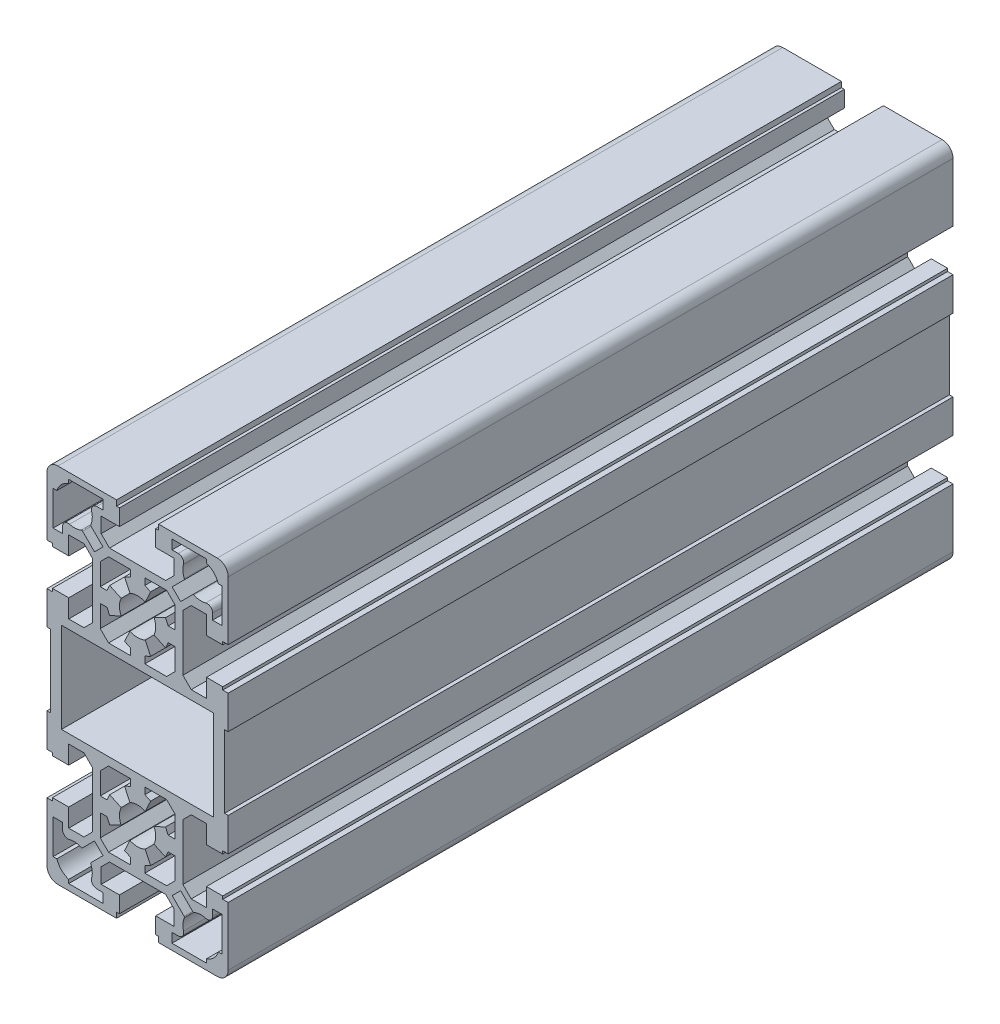
from build123d import *

# Parameters (mm, degrees)
SKETCH1_W          = 42
SKETCH1_H          = 24.9
BASE_EXTRUDE_DEPTH = 200


with BuildPart() as part:
    # Sketch1 → Base-Extrude (new body)
    with BuildSketch(Plane.XY):
        with BuildLine():
            Line((25, 72), (25, 55.8))
            Line((25, 55.8), (23.5, 55.8))
            Line((23.5, 55.8), (23.5, 55))
            Line((23.5, 55), (19, 55))
            Line((19, 55), (19, 60.05))
            Line((19, 60.05), (14.8, 60.05))
            Line((14.8, 60.05), (12.5, 57.75))
            Line((12.5, 57.75), (12.5, 42.25))
            Line((12.5, 42.25), (14.8, 39.95))
            Line((14.8, 39.95), (19, 39.95))
            Line((19, 39.95), (19, 45))
            Line((19, 45), (23.5, 45))
            Line((23.5, 45), (23.5, 44.2))
            Line((23.5, 44.2), (25, 44.2))
            Line((25, 44.2), (25, 35))
            Line((25, 35), (24, 35))
            Line((24, 35), (24, 15))
            Line((24, 15), (25, 15))
            Line((25, 15), (25, 5.8))
            Line((25, 5.8), (23.5, 5.8))
            Line((23.5, 5.8), (23.5, 5))
            Line((23.5, 5), (19, 5))
            Line((19, 5), (19, 10.05))
            Line((19, 10.05), (14.8, 10.05))
            Line((14.8, 10.05), (12.5, 7.75))
            Line((12.5, 7.75), (12.5, -7.75))
            Line((12.5, -7.75), (14.8, -10.05))
            Line((14.8, -10.05), (19, -10.05))
            Line((19, -10.05), (19, -5))
            Line((19, -5), (23.5, -5))
            Line((23.5, -5), (23.5, -5.8))
            Line((23.5, -5.8), (25, -5.8))
            Line((25, -5.8), (25, -22))
            ThreePointArc((25, -22), (24.121320344, -24.121320344), (22, -25))
            Line((22, -25), (5.8, -25))
            Line((5.8, -25), (5.8, -23.5))
            Line((5.8, -23.5), (5, -23.5))
            Line((5, -23.5), (5, -19))
            Line((5, -19), (10.05, -19))
            Line((10.05, -19), (10.05, -14.8))
            Line((10.05, -14.8), (7.75, -12.5))
            Line((7.75, -12.5), (-7.75, -12.5))
            Line((-7.75, -12.5), (-10.05, -14.8))
            Line((-10.05, -14.8), (-10.05, -19))
            Line((-10.05, -19), (-5, -19))
            Line((-5, -19), (-5, -23.5))
            Line((-5, -23.5), (-5.8, -23.5))
            Line((-5.8, -23.5), (-5.8, -25))
            Line((-5.8, -25), (-22, -25))
            ThreePointArc((-22, -25), (-24.121320344, -24.121320344), (-25, -22))
            Line((-25, -22), (-25, -5.8))
            Line((-25, -5.8), (-23.5, -5.8))
            Line((-23.5, -5.8), (-23.5, -5))
            Line((-23.5, -5), (-19, -5))
            Line((-19, -5), (-19, -10.05))
            Line((-19, -10.05), (-14.8, -10.05))
            Line((-14.8, -10.05), (-12.5, -7.75))
            Line((-12.5, -7.75), (-12.5, 7.75))
            Line((-12.5, 7.75), (-14.8, 10.05))
            Line((-14.8, 10.05), (-19, 10.05))
            Line((-19, 10.05), (-19, 5))
            Line((-19, 5), (-23.5, 5))
            Line((-23.5, 5), (-23.5, 5.8))
            Line((-23.5, 5.8), (-25, 5.8))
            Line((-25, 5.8), (-25, 15))
            Line((-25, 15), (-24, 15))
            Line((-24, 15), (-24, 35))
            Line((-24, 35), (-25, 35))
            Line((-25, 35), (-25, 44.2))
            Line((-25, 44.2), (-23.5, 44.2))
            Line((-23.5, 44.2), (-23.5, 45))
            Line((-23.5, 45), (-19, 45))
            Line((-19, 45), (-19, 39.95))
            Line((-19, 39.95), (-14.8, 39.95))
            Line((-14.8, 39.95), (-12.5, 42.25))
            Line((-12.5, 42.25), (-12.5, 57.75))
            Line((-12.5, 57.75), (-14.8, 60.05))
            Line((-14.8, 60.05), (-19, 60.05))
            Line((-19, 60.05), (-19, 55))
            Line((-19, 55), (-23.5, 55))
            Line((-23.5, 55), (-23.5, 55.8))
            Line((-23.5, 55.8), (-25, 55.8))
            Line((-25, 55.8), (-25, 72))
            ThreePointArc((-25, 72), (-24.121320344, 74.121320344), (-22, 75))
            Line((-22, 75), (-5.8, 75))
            Line((-5.8, 75), (-5.8, 73.5))
            Line((-5.8, 73.5), (-5, 73.5))
            Line((-5, 73.5), (-5, 69))
            Line((-5, 69), (-10.05, 69))
            Line((-10.05, 69), (-10.05, 64.8))
            Line((-10.05, 64.8), (-7.75, 62.5))
            Line((-7.75, 62.5), (7.75, 62.5))
            Line((7.75, 62.5), (10.05, 64.8))
            Line((10.05, 64.8), (10.05, 69))
            Line((10.05, 69), (5, 69))
            Line((5, 69), (5, 73.5))
            Line((5, 73.5), (5.8, 73.5))
            Line((5.8, 73.5), (5.8, 75))
            Line((5.8, 75), (22, 75))
            ThreePointArc((22, 75), (24.121320344, 74.121320344), (25, 72))
        make_face()
        with BuildLine():
            Line((9.538856429, 61.884693373), (12.844749681, 65.190586625))
            ThreePointArc((12.844749681, 65.190586625), (12.927259816, 65.346274066), (12.908129855, 65.521432697))
            ThreePointArc((12.908129855, 65.521432697), (12.512637816, 67.144727644), (12.674034726, 68.807692308))
            ThreePointArc((12.674034726, 68.807692308), (12.417559866, 70.11146543), (11.226245143, 70.7))
            Line((11.226245143, 70.7), (9.5, 70.7))
            Line((9.5, 70.7), (9.5, 73.3))
            Line((9.5, 73.3), (19, 73.3))
            Line((19, 73.3), (19, 72.269696007))
            ThreePointArc((19, 72.269696007), (21.035533906, 71.035533906), (22.269696007, 69))
            Line((22.269696007, 69), (23.3, 69))
            Line((23.3, 69), (23.3, 59.5))
            Line((23.3, 59.5), (20.7, 59.5))
            Line((20.7, 59.5), (20.7, 61.226245143))
            ThreePointArc((20.7, 61.226245143), (20.11146543, 62.417559866), (18.807692308, 62.674034726))
            ThreePointArc((18.807692308, 62.674034726), (17.144727644, 62.512637816), (15.521432697, 62.908129855))
            ThreePointArc((15.521432697, 62.908129855), (15.346274066, 62.927259816), (15.190586625, 62.844749681))
            Line((15.190586625, 62.844749681), (11.884693373, 59.538856429))
            Line((11.884693373, 59.538856429), (9.538856429, 61.884693373))
        make_face(mode=Mode.SUBTRACT)
        with BuildLine():
            Line((-12.844749681, 65.190586625), (-9.538856429, 61.884693373))
            Line((-9.538856429, 61.884693373), (-11.884693373, 59.538856429))
            Line((-11.884693373, 59.538856429), (-15.190586625, 62.844749681))
            ThreePointArc((-15.190586625, 62.844749681), (-15.346274066, 62.927259816), (-15.521432697, 62.908129855))
            ThreePointArc((-15.521432697, 62.908129855), (-17.144727644, 62.512637816), (-18.807692308, 62.674034726))
            ThreePointArc((-18.807692308, 62.674034726), (-20.11146543, 62.417559866), (-20.7, 61.226245143))
            Line((-20.7, 61.226245143), (-20.7, 59.5))
            Line((-20.7, 59.5), (-23.3, 59.5))
            Line((-23.3, 59.5), (-23.3, 69))
            Line((-23.3, 69), (-22.269696007, 69))
            ThreePointArc((-22.269696007, 69), (-21.035533906, 71.035533906), (-19, 72.269696007))
            Line((-19, 72.269696007), (-19, 73.3))
            Line((-19, 73.3), (-9.5, 73.3))
            Line((-9.5, 73.3), (-9.5, 70.7))
            Line((-9.5, 70.7), (-11.226245143, 70.7))
            ThreePointArc((-11.226245143, 70.7), (-12.417559866, 70.11146543), (-12.674034726, 68.807692308))
            ThreePointArc((-12.674034726, 68.807692308), (-12.512637816, 67.144727644), (-12.908129855, 65.521432697))
            ThreePointArc((-12.908129855, 65.521432697), (-12.927259816, 65.346274066), (-12.844749681, 65.190586625))
        make_face(mode=Mode.SUBTRACT)
        with BuildLine():
            Line((2, 60.3), (8.012279964, 60.3))
            Line((8.012279964, 60.3), (10.3, 58.012279964))
            Line((10.3, 58.012279964), (10.3, 52))
            Line((10.3, 52), (8.446096995, 52))
            Line((8.446096995, 52), (7.70361619, 53.592255225))
            Line((7.70361619, 53.592255225), (4.531538935, 52.113091309))
            ThreePointArc((4.531538935, 52.113091309), (5, 50), (4.531538935, 47.886908691))
            Line((4.531538935, 47.886908691), (7.70361619, 46.407744775))
            Line((7.70361619, 46.407744775), (8.446096995, 48))
            Line((8.446096995, 48), (10.3, 48))
            Line((10.3, 48), (10.3, 41.987720036))
            Line((10.3, 41.987720036), (8.012279964, 39.7))
            Line((8.012279964, 39.7), (2, 39.7))
            Line((2, 39.7), (2, 41.553903005))
            Line((2, 41.553903005), (3.592255225, 42.29638381))
            Line((3.592255225, 42.29638381), (2.113091309, 45.468461065))
            ThreePointArc((2.113091309, 45.468461065), (0, 45), (-2.113091309, 45.468461065))
            Line((-2.113091309, 45.468461065), (-3.592255225, 42.29638381))
            Line((-3.592255225, 42.29638381), (-2, 41.553903005))
            Line((-2, 41.553903005), (-2, 39.7))
            Line((-2, 39.7), (-8.012279964, 39.7))
            Line((-8.012279964, 39.7), (-10.3, 41.987720036))
            Line((-10.3, 41.987720036), (-10.3, 48))
            Line((-10.3, 48), (-8.446096995, 48))
            Line((-8.446096995, 48), (-7.70361619, 46.407744775))
            Line((-7.70361619, 46.407744775), (-4.531538935, 47.886908691))
            ThreePointArc((-4.531538935, 47.886908691), (-5, 50), (-4.531538935, 52.113091309))
            Line((-4.531538935, 52.113091309), (-7.70361619, 53.592255225))
            Line((-7.70361619, 53.592255225), (-8.446096995, 52))
            Line((-8.446096995, 52), (-10.3, 52))
            Line((-10.3, 52), (-10.3, 58.012279964))
            Line((-10.3, 58.012279964), (-8.012279964, 60.3))
            Line((-8.012279964, 60.3), (-2, 60.3))
            Line((-2, 60.3), (-2, 58.446096995))
            Line((-2, 58.446096995), (-3.592255225, 57.70361619))
            Line((-3.592255225, 57.70361619), (-2.113091309, 54.531538935))
            ThreePointArc((-2.113091309, 54.531538935), (0, 55), (2.113091309, 54.531538935))
            Line((2.113091309, 54.531538935), (3.592255225, 57.70361619))
            Line((3.592255225, 57.70361619), (2, 58.446096995))
            Line((2, 58.446096995), (2, 60.3))
        make_face(mode=Mode.SUBTRACT)
        with BuildLine():
            Line((8.012279964, -10.3), (2, -10.3))
            Line((2, -10.3), (2, -8.446096995))
            Line((2, -8.446096995), (3.592255225, -7.70361619))
            Line((3.592255225, -7.70361619), (2.113091309, -4.531538935))
            ThreePointArc((2.113091309, -4.531538935), (0, -5), (-2.113091309, -4.531538935))
            Line((-2.113091309, -4.531538935), (-3.592255225, -7.70361619))
            Line((-3.592255225, -7.70361619), (-2, -8.446096995))
            Line((-2, -8.446096995), (-2, -10.3))
            Line((-2, -10.3), (-8.012279964, -10.3))
            Line((-8.012279964, -10.3), (-10.3, -8.012279964))
            Line((-10.3, -8.012279964), (-10.3, -2))
            Line((-10.3, -2), (-8.446096995, -2))
            Line((-8.446096995, -2), (-7.70361619, -3.592255225))
            Line((-7.70361619, -3.592255225), (-4.531538935, -2.113091309))
            ThreePointArc((-4.531538935, -2.113091309), (-5, 0), (-4.531538935, 2.113091309))
            Line((-4.531538935, 2.113091309), (-7.70361619, 3.592255225))
            Line((-7.70361619, 3.592255225), (-8.446096995, 2))
            Line((-8.446096995, 2), (-10.3, 2))
            Line((-10.3, 2), (-10.3, 8.012279964))
            Line((-10.3, 8.012279964), (-8.012279964, 10.3))
            Line((-8.012279964, 10.3), (-2, 10.3))
            Line((-2, 10.3), (-2, 8.446096995))
            Line((-2, 8.446096995), (-3.592255225, 7.70361619))
            Line((-3.592255225, 7.70361619), (-2.113091309, 4.531538935))
            ThreePointArc((-2.113091309, 4.531538935), (0, 5), (2.113091309, 4.531538935))
            Line((2.113091309, 4.531538935), (3.592255225, 7.70361619))
            Line((3.592255225, 7.70361619), (2, 8.446096995))
            Line((2, 8.446096995), (2, 10.3))
            Line((2, 10.3), (8.012279964, 10.3))
            Line((8.012279964, 10.3), (10.3, 8.012279964))
            Line((10.3, 8.012279964), (10.3, 2))
            Line((10.3, 2), (8.446096995, 2))
            Line((8.446096995, 2), (7.70361619, 3.592255225))
            Line((7.70361619, 3.592255225), (4.531538935, 2.113091309))
            ThreePointArc((4.531538935, 2.113091309), (5, 0), (4.531538935, -2.113091309))
            Line((4.531538935, -2.113091309), (7.70361619, -3.592255225))
            Line((7.70361619, -3.592255225), (8.446096995, -2))
            Line((8.446096995, -2), (10.3, -2))
            Line((10.3, -2), (10.3, -8.012279964))
            Line((10.3, -8.012279964), (8.012279964, -10.3))
        make_face(mode=Mode.SUBTRACT)
        with Locations((0, 25)):
            Rectangle(SKETCH1_W, SKETCH1_H, mode=Mode.SUBTRACT)
        with BuildLine():
            Line((-23.3, -19), (-23.3, -9.5))
            Line((-23.3, -9.5), (-20.7, -9.5))
            Line((-20.7, -9.5), (-20.7, -11.226245143))
            ThreePointArc((-20.7, -11.226245143), (-20.11146543, -12.417559866), (-18.807692308, -12.674034726))
            ThreePointArc((-18.807692308, -12.674034726), (-17.144727644, -12.512637816), (-15.521432697, -12.908129855))
            ThreePointArc((-15.521432697, -12.908129855), (-15.346274066, -12.927259816), (-15.190586625, -12.844749681))
            Line((-15.190586625, -12.844749681), (-11.884693373, -9.538856429))
            Line((-11.884693373, -9.538856429), (-9.538856429, -11.884693373))
            Line((-9.538856429, -11.884693373), (-12.844749681, -15.190586625))
            ThreePointArc((-12.844749681, -15.190586625), (-12.927259816, -15.346274066), (-12.908129855, -15.521432697))
            ThreePointArc((-12.908129855, -15.521432697), (-12.512637816, -17.144727644), (-12.674034726, -18.807692308))
            ThreePointArc((-12.674034726, -18.807692308), (-12.417559866, -20.11146543), (-11.226245143, -20.7))
            Line((-11.226245143, -20.7), (-9.5, -20.7))
            Line((-9.5, -20.7), (-9.5, -23.3))
            Line((-9.5, -23.3), (-19, -23.3))
            Line((-19, -23.3), (-19, -22.269696007))
            ThreePointArc((-19, -22.269696007), (-21.035533906, -21.035533906), (-22.269696007, -19))
            Line((-22.269696007, -19), (-23.3, -19))
        make_face(mode=Mode.SUBTRACT)
        with BuildLine():
            Line((23.3, -9.5), (23.3, -19))
            Line((23.3, -19), (22.269696007, -19))
            ThreePointArc((22.269696007, -19), (21.035533906, -21.035533906), (19, -22.269696007))
            Line((19, -22.269696007), (19, -23.3))
            Line((19, -23.3), (9.5, -23.3))
            Line((9.5, -23.3), (9.5, -20.7))
            Line((9.5, -20.7), (11.226245143, -20.7))
            ThreePointArc((11.226245143, -20.7), (12.417559866, -20.11146543), (12.674034726, -18.807692308))
            ThreePointArc((12.674034726, -18.807692308), (12.512637816, -17.144727644), (12.908129855, -15.521432697))
            ThreePointArc((12.908129855, -15.521432697), (12.927259816, -15.346274066), (12.844749681, -15.190586625))
            Line((12.844749681, -15.190586625), (9.538856429, -11.884693373))
            Line((9.538856429, -11.884693373), (11.884693373, -9.538856429))
            Line((11.884693373, -9.538856429), (15.190586625, -12.844749681))
            ThreePointArc((15.190586625, -12.844749681), (15.346274066, -12.927259816), (15.521432697, -12.908129855))
            ThreePointArc((15.521432697, -12.908129855), (17.144727644, -12.512637816), (18.807692308, -12.674034726))
            ThreePointArc((18.807692308, -12.674034726), (20.11146543, -12.417559866), (20.7, -11.226245143))
            Line((20.7, -11.226245143), (20.7, -9.5))
            Line((20.7, -9.5), (23.3, -9.5))
        make_face(mode=Mode.SUBTRACT)
    extrude(amount=BASE_EXTRUDE_DEPTH)


solid = part.part
